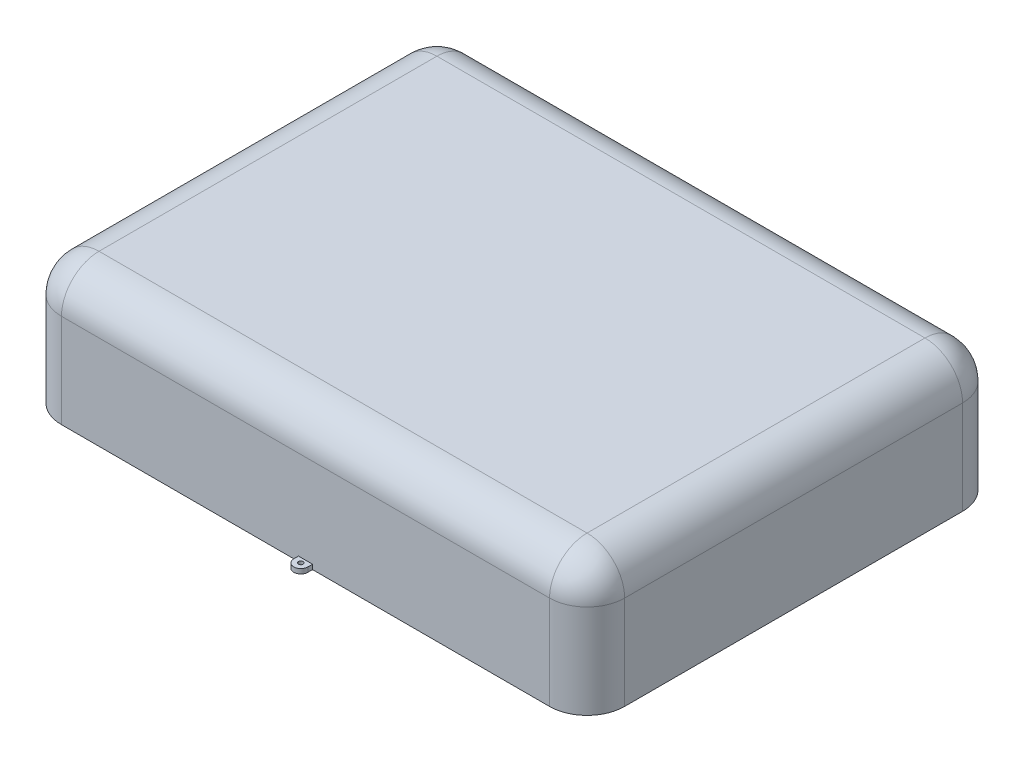
from build123d import *

# Parameters (mm, degrees)
SKETCH1_W                = 762
SKETCH1_H                = 558.8
BOSS_EXTRUDE1_DEPTH      = 177.8
FILLET9_R                = 50.8
SHELL1_T                 = -4.7625
SKETCH4_R                = 30.1625
BOSS_EXTRUDE3_DEPTH      = 77.7875
SKETCH5_R                = 25.4
SKETCH5_R_2              = 19.685
SKETCH5_R_3              = 14.9225
CUT_EXTRUDE1_DEPTH       = 12.7
FILLET13_R               = 2.54
SKETCH6_R                = 6.35
BOSS_EXTRUDE4_DEPTH      = 273.05
BOSS_EXTRUDE4_DEPTH_BACK = 273.05
SKETCH7_W                = 133.35
SKETCH7_H                = 19.05
SKETCH7_W_2              = 12.7
CUT_EXTRUDE2_DEPTH       = 203.2
CUT_EXTRUDE3_DEPTH       = 12.7
LPATTERN1_COUNT          = 3
LPATTERN1_PITCH          = 50.8
MIRROR1_COPY_1_DEPTH     = 12.7
MIRROR1_COPY_2_DEPTH     = 12.7
CUT_EXTRUDE4_DEPTH       = 12.7
LPATTERN2_COUNT          = 3
LPATTERN2_PITCH          = 50.8
MIRROR2_COPY_1_DEPTH     = 12.7
MIRROR2_COPY_2_DEPTH     = 12.7
FILLET14_R               = 2.54
SKETCH11_R               = 14.9225
CUT_EXTRUDE5_DEPTH       = 65.0875
BOSS_EXTRUDE5_DEPTH      = 1.27
LPATTERN3_COUNT          = 8
LPATTERN3_PITCH          = 43.18
LPATTERN3_COL_COUNT      = 8
LPATTERN3_COL_PITCH      = 43.18
MIRROR3_COPY_1_DEPTH     = 1.27
MIRROR3_COPY_2_DEPTH     = 1.27
MIRROR3_COPY_3_DEPTH     = 1.27
MIRROR3_COPY_4_DEPTH     = 1.27
MIRROR3_COPY_5_DEPTH     = 1.27
MIRROR3_COPY_6_DEPTH     = 1.27
MIRROR3_COPY_7_DEPTH     = 1.27
MIRROR3_COPY_8_DEPTH     = 1.27
MIRROR3_COPY_9_DEPTH     = 1.27
MIRROR3_COPY_10_DEPTH    = 1.27
MIRROR3_COPY_11_DEPTH    = 1.27
MIRROR3_COPY_12_DEPTH    = 1.27
MIRROR3_COPY_13_DEPTH    = 1.27
MIRROR3_COPY_14_DEPTH    = 1.27
BOSS_EXTRUDE6_DEPTH      = 1.27
LPATTERN4_COUNT          = 5
LPATTERN4_PITCH          = 44.45
LPATTERN4_COL_COUNT      = 5
LPATTERN4_COL_PITCH      = 44.45
MIRROR4_COPY_1_DEPTH     = 1.27
MIRROR4_COPY_2_DEPTH     = 1.27
MIRROR4_COPY_3_DEPTH     = 1.27
MIRROR4_COPY_4_DEPTH     = 1.27
MIRROR4_COPY_5_DEPTH     = 1.27
MIRROR4_COPY_6_DEPTH     = 1.27
MIRROR4_COPY_7_DEPTH     = 1.27
MIRROR4_COPY_8_DEPTH     = 1.27
SKETCH14_R               = 3.175
BOSS_EXTRUDE7_DEPTH      = 6.35


with BuildPart() as part:
    # Sketch1 → Boss-Extrude1 (new body)
    with BuildSketch(Plane(origin=(0, 0, 0), x_dir=(1, 0, 0), z_dir=(0, 1, 0))):
        Rectangle(SKETCH1_W, SKETCH1_H)
    extrude(amount=BOSS_EXTRUDE1_DEPTH)

    # Fillet9
    fillet9_edges = [part.edges().sort_by_distance(p)[0] for p in [
        (381, 177.8, 0),
        (0, 177.8, -279.4),
        (-381, 177.8, 0),
        (-381, 88.9, -279.4),
        (381, 88.9, -279.4),
        (381, 88.9, 279.4),
        (-381, 88.9, 279.4),
        (0, 177.8, 279.4),
    ]]
    fillet(fillet9_edges, radius=FILLET9_R)

    # Shell1
    shell1_openings = [part.faces().sort_by_distance(p)[0] for p in [
        (0, 0, 0),
    ]]
    offset(amount=SHELL1_T, openings=shell1_openings, kind=Kind.INTERSECTION)

    # Sketch4 → Boss-Extrude3 (add)
    with BuildSketch(Plane.XZ.offset(-173.0375)):
        with Locations((114.3, -68.58)):
            Circle(SKETCH4_R)
        with Locations((-114.3, -68.58)):
            Circle(SKETCH4_R)
        with Locations((114.3, 68.58)):
            Circle(SKETCH4_R)
        with Locations((-114.3, 68.58)):
            Circle(SKETCH4_R)
    extrude(amount=BOSS_EXTRUDE3_DEPTH)

    # Sketch5 → Cut-Extrude1 (cut)
    with BuildSketch(Plane.XZ.offset(-95.25)):
        with Locations((114.3, -68.58)):
            Circle(SKETCH5_R)
        with Locations((114.3, -68.58)):
            Circle(SKETCH5_R_2, mode=Mode.SUBTRACT)
        with Locations((114.3, -68.58)):
            Circle(SKETCH5_R_3)
        with Locations((-114.3, -68.58)):
            Circle(SKETCH5_R)
        with Locations((-114.3, -68.58)):
            Circle(SKETCH5_R_2, mode=Mode.SUBTRACT)
        with Locations((-114.3, -68.58)):
            Circle(SKETCH5_R_3)
        with Locations((114.3, 68.58)):
            Circle(SKETCH5_R)
        with Locations((114.3, 68.58)):
            Circle(SKETCH5_R_2, mode=Mode.SUBTRACT)
        with Locations((114.3, 68.58)):
            Circle(SKETCH5_R_3)
        with Locations((-114.3, 68.58)):
            Circle(SKETCH5_R)
        with Locations((-114.3, 68.58)):
            Circle(SKETCH5_R_2, mode=Mode.SUBTRACT)
        with Locations((-114.3, 68.58)):
            Circle(SKETCH5_R_3)
    extrude(amount=-CUT_EXTRUDE1_DEPTH, mode=Mode.SUBTRACT)

    # Fillet13
    fillet13_edges = [part.edges().sort_by_distance(p)[0] for p in [
        (84.1375, 173.0375, -68.58),
        (-144.4625, 173.0375, -68.58),
        (84.1375, 173.0375, 68.58),
        (-144.4625, 173.0375, 68.58),
    ]]
    fillet(fillet13_edges, radius=FILLET13_R)

    # Sketch6 → Boss-Extrude4 (add, two sides)
    with BuildSketch(Plane(origin=(0, 0, 0), x_dir=(0, 0, -1), z_dir=(1, 0, 0))) as boss_extrude4_sk:
        with BuildLine():
            Line((288.925, 9.525), (288.925, 30.48))
            Line((288.925, 30.48), (279.4, 30.48))
            Line((279.4, 30.48), (279.4, 0))
            ThreePointArc((279.4, 0), (295.660192091, -6.735192091), (288.925, 9.525))
        make_face()
        with Locations((288.925, 0)):
            Circle(SKETCH6_R, mode=Mode.SUBTRACT)
    extrude(amount=BOSS_EXTRUDE4_DEPTH)
    extrude(boss_extrude4_sk.sketch, amount=-BOSS_EXTRUDE4_DEPTH_BACK)

    # Sketch7 → Cut-Extrude2 (cut)
    with BuildSketch(Plane(origin=(0, 177.8, 0), x_dir=(1, 0, 0), z_dir=(0, 1, 0))):
        with Locations((66.675, 288.925)):
            Rectangle(SKETCH7_W, SKETCH7_H)
        with Locations((-66.675, 288.925)):
            Rectangle(SKETCH7_W, SKETCH7_H)
        with Locations((-152.4, 288.925)):
            Rectangle(SKETCH7_W_2, SKETCH7_H)
        with Locations((-177.8, 288.925)):
            Rectangle(SKETCH7_W_2, SKETCH7_H)
        with Locations((-203.2, 288.925)):
            Rectangle(SKETCH7_W_2, SKETCH7_H)
        with Locations((-228.6, 288.925)):
            Rectangle(SKETCH7_W_2, SKETCH7_H)
        with Locations((-254, 288.925)):
            Rectangle(SKETCH7_W_2, SKETCH7_H)
        with Locations((152.4, 288.925)):
            Rectangle(SKETCH7_W_2, SKETCH7_H)
        with Locations((177.8, 288.925)):
            Rectangle(SKETCH7_W_2, SKETCH7_H)
        with Locations((203.2, 288.925)):
            Rectangle(SKETCH7_W_2, SKETCH7_H)
        with Locations((228.6, 288.925)):
            Rectangle(SKETCH7_W_2, SKETCH7_H)
        with Locations((254, 288.925)):
            Rectangle(SKETCH7_W_2, SKETCH7_H)
    extrude(amount=-CUT_EXTRUDE2_DEPTH, mode=Mode.SUBTRACT)

    # Sketch8 → Cut-Extrude3 (cut)
    with BuildSketch(Plane.ZY.offset(273.05)):
        with BuildLine():
            Line((-288.925, 9.525), (-288.925, 30.48))
            Line((-288.925, 30.48), (-282.575, 30.48))
            Line((-282.575, 30.48), (-282.575, 7.099515829))
            ThreePointArc((-282.575, 7.099515829), (-285.526269595, 8.897991719), (-288.925, 9.525))
        make_face()
        with BuildLine():
            Line((-295.275, 0), (-298.45, 0))
            ThreePointArc((-298.45, 0), (-288.925, -9.525), (-279.4, 0))
            Line((-279.4, 0), (-282.575, 0))
            ThreePointArc((-282.575, 0), (-288.925, -6.35), (-295.275, 0))
        make_face()
    cut_extrude3 = extrude(amount=-CUT_EXTRUDE3_DEPTH, mode=Mode.SUBTRACT)

    # LPattern1: Cut-Extrude3 ×3
    with Locations(*[(i * LPATTERN1_PITCH, 0, 0) for i in range(1, LPATTERN1_COUNT)]):
        add(cut_extrude3, mode=Mode.SUBTRACT)

    # Mirror1: Cut-Extrude3 across plane
    add(cut_extrude3.mirror(Plane(origin=(0, 0, 0), x_dir=(0, 0, 1), z_dir=(1, 0, 0))), mode=Mode.SUBTRACT)

    # Mirror1 copy 1 sketch → Mirror1 copy 1 (cut)
    with BuildSketch(Plane(origin=(222.25, 0, 0), x_dir=(0, 0, 1), z_dir=(1, 0, 0))):
        with BuildLine():
            Line((-288.925, -9.525), (-288.925, -30.48))
            Line((-288.925, -30.48), (-282.575, -30.48))
            Line((-282.575, -30.48), (-282.575, -7.099515829))
            ThreePointArc((-282.575, -7.099515829), (-285.526269595, -8.897991719), (-288.925, -9.525))
        make_face()
        with BuildLine():
            Line((-295.275, 0), (-298.45, 0))
            ThreePointArc((-298.45, 0), (-288.925, 9.525), (-279.4, 0))
            Line((-279.4, 0), (-282.575, 0))
            ThreePointArc((-282.575, 0), (-288.925, 6.35), (-295.275, 0))
        make_face()
    extrude(amount=-MIRROR1_COPY_1_DEPTH, mode=Mode.SUBTRACT)

    # Mirror1 copy 2 sketch → Mirror1 copy 2 (cut)
    with BuildSketch(Plane(origin=(171.45, 0, 0), x_dir=(0, 0, 1), z_dir=(1, 0, 0))):
        with BuildLine():
            Line((-288.925, -9.525), (-288.925, -30.48))
            Line((-288.925, -30.48), (-282.575, -30.48))
            Line((-282.575, -30.48), (-282.575, -7.099515829))
            ThreePointArc((-282.575, -7.099515829), (-285.526269595, -8.897991719), (-288.925, -9.525))
        make_face()
        with BuildLine():
            Line((-295.275, 0), (-298.45, 0))
            ThreePointArc((-298.45, 0), (-288.925, 9.525), (-279.4, 0))
            Line((-279.4, 0), (-282.575, 0))
            ThreePointArc((-282.575, 0), (-288.925, 6.35), (-295.275, 0))
        make_face()
    extrude(amount=-MIRROR1_COPY_2_DEPTH, mode=Mode.SUBTRACT)

    # Sketch10 → Cut-Extrude4 (cut)
    with BuildSketch(Plane.ZY.offset(247.65)):
        with BuildLine():
            Line((-298.45, 0), (-295.275, 0))
            ThreePointArc((-295.275, 0), (-288.925, 6.35), (-282.575, 0))
            Line((-282.575, 0), (-282.575, 30.48))
            Line((-282.575, 30.48), (-288.925, 30.48))
            Line((-288.925, 30.48), (-288.925, 9.525))
            ThreePointArc((-288.925, 9.525), (-295.660192091, 6.735192091), (-298.45, 0))
        make_face()
    cut_extrude4 = extrude(amount=-CUT_EXTRUDE4_DEPTH, mode=Mode.SUBTRACT)

    # LPattern2: Cut-Extrude4 ×3
    with Locations(*[(i * LPATTERN2_PITCH, 0, 0) for i in range(1, LPATTERN2_COUNT)]):
        add(cut_extrude4, mode=Mode.SUBTRACT)

    # Mirror2: Cut-Extrude4 across plane
    add(cut_extrude4.mirror(Plane(origin=(0, 0, 0), x_dir=(0, 0, 1), z_dir=(1, 0, 0))), mode=Mode.SUBTRACT)

    # Mirror2 copy 1 sketch → Mirror2 copy 1 (cut)
    with BuildSketch(Plane(origin=(196.85, 0, 0), x_dir=(0, 0, 1), z_dir=(1, 0, 0))):
        with BuildLine():
            Line((-298.45, 0), (-295.275, 0))
            ThreePointArc((-295.275, 0), (-288.925, -6.35), (-282.575, 0))
            Line((-282.575, 0), (-282.575, -30.48))
            Line((-282.575, -30.48), (-288.925, -30.48))
            Line((-288.925, -30.48), (-288.925, -9.525))
            ThreePointArc((-288.925, -9.525), (-295.660192091, -6.735192091), (-298.45, 0))
        make_face()
    extrude(amount=-MIRROR2_COPY_1_DEPTH, mode=Mode.SUBTRACT)

    # Mirror2 copy 2 sketch → Mirror2 copy 2 (cut)
    with BuildSketch(Plane(origin=(146.05, 0, 0), x_dir=(0, 0, 1), z_dir=(1, 0, 0))):
        with BuildLine():
            Line((-298.45, 0), (-295.275, 0))
            ThreePointArc((-295.275, 0), (-288.925, -6.35), (-282.575, 0))
            Line((-282.575, 0), (-282.575, -30.48))
            Line((-282.575, -30.48), (-288.925, -30.48))
            Line((-288.925, -30.48), (-288.925, -9.525))
            ThreePointArc((-288.925, -9.525), (-295.660192091, -6.735192091), (-298.45, 0))
        make_face()
    extrude(amount=-MIRROR2_COPY_2_DEPTH, mode=Mode.SUBTRACT)

    # Fillet14
    fillet14_edges = [part.edges().sort_by_distance(p)[0] for p in [
        (-241.3, 0, -279.4),
        (-190.5, 0, -279.4),
        (-139.7, 0, -279.4),
        (139.7, 0, -279.4),
        (190.5, 0, -279.4),
        (241.3, 0, -279.4),
        (-266.7, 7.099515829, -282.575),
        (-215.9, 7.099515829, -282.575),
        (-165.1, 7.099515829, -282.575),
        (266.7, 7.099515829, -282.575),
        (215.9, 7.099515829, -282.575),
        (165.1, 7.099515829, -282.575),
    ]]
    fillet(fillet14_edges, radius=FILLET14_R)

    # Sketch11 → Cut-Extrude5 (cut)
    with BuildSketch(Plane.XZ.offset(-107.95)):
        with Locations((-114.3, 68.58)):
            Circle(SKETCH11_R)
        with Locations((-114.3, -68.58)):
            Circle(SKETCH11_R)
        with Locations((114.3, -68.58)):
            Circle(SKETCH11_R)
        with Locations((114.3, 68.58)):
            Circle(SKETCH11_R)
    extrude(amount=-CUT_EXTRUDE5_DEPTH, mode=Mode.SUBTRACT)

    # Sketch12 → Boss-Extrude5 (add, symmetric)
    with BuildSketch(Plane(origin=(0, 0, 0), x_dir=(0, 0, -1), z_dir=(1, 0, 0))):
        with BuildLine():
            Line((228.6, 173.0375), (274.6375, 109.5375))
            Line((274.6375, 109.5375), (274.6375, 127))
            ThreePointArc((274.6375, 127), (261.153428439, 159.553428439), (228.6, 173.0375))
        make_face()
    boss_extrude5 = extrude(amount=BOSS_EXTRUDE5_DEPTH, both=True)

    # LPattern3: Boss-Extrude5 ×8
    with Locations(*[(i * LPATTERN3_PITCH, 0, 0) for i in range(1, LPATTERN3_COUNT)]):
        add(boss_extrude5)

    # LPattern3 col: Boss-Extrude5 ×8
    with Locations(*[(-i * LPATTERN3_COL_PITCH, 0, 0) for i in range(1, LPATTERN3_COL_COUNT)]):
        add(boss_extrude5)

    # Mirror3: Boss-Extrude5 across plane
    add(boss_extrude5.mirror(Plane.XY))

    # Mirror3 copy 1 sketch → Mirror3 copy 1 (add, symmetric)
    with BuildSketch(Plane(origin=(43.18, 0, 0), x_dir=(0, 0, 1), z_dir=(1, 0, 0))):
        with BuildLine():
            Line((228.6, -173.0375), (274.6375, -109.5375))
            Line((274.6375, -109.5375), (274.6375, -127))
            ThreePointArc((274.6375, -127), (261.153428439, -159.553428439), (228.6, -173.0375))
        make_face()
    extrude(amount=MIRROR3_COPY_1_DEPTH, both=True)

    # Mirror3 copy 2 sketch → Mirror3 copy 2 (add, symmetric)
    with BuildSketch(Plane(origin=(86.36, 0, 0), x_dir=(0, 0, 1), z_dir=(1, 0, 0))):
        with BuildLine():
            Line((228.6, -173.0375), (274.6375, -109.5375))
            Line((274.6375, -109.5375), (274.6375, -127))
            ThreePointArc((274.6375, -127), (261.153428439, -159.553428439), (228.6, -173.0375))
        make_face()
    extrude(amount=MIRROR3_COPY_2_DEPTH, both=True)

    # Mirror3 copy 3 sketch → Mirror3 copy 3 (add, symmetric)
    with BuildSketch(Plane(origin=(129.54, 0, 0), x_dir=(0, 0, 1), z_dir=(1, 0, 0))):
        with BuildLine():
            Line((228.6, -173.0375), (274.6375, -109.5375))
            Line((274.6375, -109.5375), (274.6375, -127))
            ThreePointArc((274.6375, -127), (261.153428439, -159.553428439), (228.6, -173.0375))
        make_face()
    extrude(amount=MIRROR3_COPY_3_DEPTH, both=True)

    # Mirror3 copy 4 sketch → Mirror3 copy 4 (add, symmetric)
    with BuildSketch(Plane(origin=(172.72, 0, 0), x_dir=(0, 0, 1), z_dir=(1, 0, 0))):
        with BuildLine():
            Line((228.6, -173.0375), (274.6375, -109.5375))
            Line((274.6375, -109.5375), (274.6375, -127))
            ThreePointArc((274.6375, -127), (261.153428439, -159.553428439), (228.6, -173.0375))
        make_face()
    extrude(amount=MIRROR3_COPY_4_DEPTH, both=True)

    # Mirror3 copy 5 sketch → Mirror3 copy 5 (add, symmetric)
    with BuildSketch(Plane(origin=(215.9, 0, 0), x_dir=(0, 0, 1), z_dir=(1, 0, 0))):
        with BuildLine():
            Line((228.6, -173.0375), (274.6375, -109.5375))
            Line((274.6375, -109.5375), (274.6375, -127))
            ThreePointArc((274.6375, -127), (261.153428439, -159.553428439), (228.6, -173.0375))
        make_face()
    extrude(amount=MIRROR3_COPY_5_DEPTH, both=True)

    # Mirror3 copy 6 sketch → Mirror3 copy 6 (add, symmetric)
    with BuildSketch(Plane(origin=(259.08, 0, 0), x_dir=(0, 0, 1), z_dir=(1, 0, 0))):
        with BuildLine():
            Line((228.6, -173.0375), (274.6375, -109.5375))
            Line((274.6375, -109.5375), (274.6375, -127))
            ThreePointArc((274.6375, -127), (261.153428439, -159.553428439), (228.6, -173.0375))
        make_face()
    extrude(amount=MIRROR3_COPY_6_DEPTH, both=True)

    # Mirror3 copy 7 sketch → Mirror3 copy 7 (add, symmetric)
    with BuildSketch(Plane(origin=(302.26, 0, 0), x_dir=(0, 0, 1), z_dir=(1, 0, 0))):
        with BuildLine():
            Line((228.6, -173.0375), (274.6375, -109.5375))
            Line((274.6375, -109.5375), (274.6375, -127))
            ThreePointArc((274.6375, -127), (261.153428439, -159.553428439), (228.6, -173.0375))
        make_face()
    extrude(amount=MIRROR3_COPY_7_DEPTH, both=True)

    # Mirror3 copy 8 sketch → Mirror3 copy 8 (add, symmetric)
    with BuildSketch(Plane(origin=(-43.18, 0, 0), x_dir=(0, 0, 1), z_dir=(1, 0, 0))):
        with BuildLine():
            Line((228.6, -173.0375), (274.6375, -109.5375))
            Line((274.6375, -109.5375), (274.6375, -127))
            ThreePointArc((274.6375, -127), (261.153428439, -159.553428439), (228.6, -173.0375))
        make_face()
    extrude(amount=MIRROR3_COPY_8_DEPTH, both=True)

    # Mirror3 copy 9 sketch → Mirror3 copy 9 (add, symmetric)
    with BuildSketch(Plane(origin=(-86.36, 0, 0), x_dir=(0, 0, 1), z_dir=(1, 0, 0))):
        with BuildLine():
            Line((228.6, -173.0375), (274.6375, -109.5375))
            Line((274.6375, -109.5375), (274.6375, -127))
            ThreePointArc((274.6375, -127), (261.153428439, -159.553428439), (228.6, -173.0375))
        make_face()
    extrude(amount=MIRROR3_COPY_9_DEPTH, both=True)

    # Mirror3 copy 10 sketch → Mirror3 copy 10 (add, symmetric)
    with BuildSketch(Plane(origin=(-129.54, 0, 0), x_dir=(0, 0, 1), z_dir=(1, 0, 0))):
        with BuildLine():
            Line((228.6, -173.0375), (274.6375, -109.5375))
            Line((274.6375, -109.5375), (274.6375, -127))
            ThreePointArc((274.6375, -127), (261.153428439, -159.553428439), (228.6, -173.0375))
        make_face()
    extrude(amount=MIRROR3_COPY_10_DEPTH, both=True)

    # Mirror3 copy 11 sketch → Mirror3 copy 11 (add, symmetric)
    with BuildSketch(Plane(origin=(-172.72, 0, 0), x_dir=(0, 0, 1), z_dir=(1, 0, 0))):
        with BuildLine():
            Line((228.6, -173.0375), (274.6375, -109.5375))
            Line((274.6375, -109.5375), (274.6375, -127))
            ThreePointArc((274.6375, -127), (261.153428439, -159.553428439), (228.6, -173.0375))
        make_face()
    extrude(amount=MIRROR3_COPY_11_DEPTH, both=True)

    # Mirror3 copy 12 sketch → Mirror3 copy 12 (add, symmetric)
    with BuildSketch(Plane(origin=(-215.9, 0, 0), x_dir=(0, 0, 1), z_dir=(1, 0, 0))):
        with BuildLine():
            Line((228.6, -173.0375), (274.6375, -109.5375))
            Line((274.6375, -109.5375), (274.6375, -127))
            ThreePointArc((274.6375, -127), (261.153428439, -159.553428439), (228.6, -173.0375))
        make_face()
    extrude(amount=MIRROR3_COPY_12_DEPTH, both=True)

    # Mirror3 copy 13 sketch → Mirror3 copy 13 (add, symmetric)
    with BuildSketch(Plane(origin=(-259.08, 0, 0), x_dir=(0, 0, 1), z_dir=(1, 0, 0))):
        with BuildLine():
            Line((228.6, -173.0375), (274.6375, -109.5375))
            Line((274.6375, -109.5375), (274.6375, -127))
            ThreePointArc((274.6375, -127), (261.153428439, -159.553428439), (228.6, -173.0375))
        make_face()
    extrude(amount=MIRROR3_COPY_13_DEPTH, both=True)

    # Mirror3 copy 14 sketch → Mirror3 copy 14 (add, symmetric)
    with BuildSketch(Plane(origin=(-302.26, 0, 0), x_dir=(0, 0, 1), z_dir=(1, 0, 0))):
        with BuildLine():
            Line((228.6, -173.0375), (274.6375, -109.5375))
            Line((274.6375, -109.5375), (274.6375, -127))
            ThreePointArc((274.6375, -127), (261.153428439, -159.553428439), (228.6, -173.0375))
        make_face()
    extrude(amount=MIRROR3_COPY_14_DEPTH, both=True)

    # Sketch13 → Boss-Extrude6 (add, symmetric)
    with BuildSketch(Plane.XY):
        with BuildLine():
            Line((330.2, 173.0375), (376.2375, 109.5375))
            Line((376.2375, 109.5375), (376.2375, 127))
            ThreePointArc((376.2375, 127), (362.753428439, 159.553428439), (330.2, 173.0375))
        make_face()
    boss_extrude6 = extrude(amount=BOSS_EXTRUDE6_DEPTH, both=True)

    # LPattern4: Boss-Extrude6 ×5
    with Locations(*[(0, 0, i * LPATTERN4_PITCH) for i in range(1, LPATTERN4_COUNT)]):
        add(boss_extrude6)

    # LPattern4 col: Boss-Extrude6 ×5
    with Locations(*[(0, 0, -i * LPATTERN4_COL_PITCH) for i in range(1, LPATTERN4_COL_COUNT)]):
        add(boss_extrude6)

    # Mirror4: Boss-Extrude6 across plane
    add(boss_extrude6.mirror(Plane(origin=(0, 0, 0), x_dir=(0, 0, 1), z_dir=(1, 0, 0))))

    # Mirror4 copy 1 sketch → Mirror4 copy 1 (add, symmetric)
    with BuildSketch(Plane(origin=(0, 0, 44.45), x_dir=(-1, 0, 0), z_dir=(0, 0, 1))):
        with BuildLine():
            Line((330.2, -173.0375), (376.2375, -109.5375))
            Line((376.2375, -109.5375), (376.2375, -127))
            ThreePointArc((376.2375, -127), (362.753428439, -159.553428439), (330.2, -173.0375))
        make_face()
    extrude(amount=MIRROR4_COPY_1_DEPTH, both=True)

    # Mirror4 copy 2 sketch → Mirror4 copy 2 (add, symmetric)
    with BuildSketch(Plane(origin=(0, 0, 88.9), x_dir=(-1, 0, 0), z_dir=(0, 0, 1))):
        with BuildLine():
            Line((330.2, -173.0375), (376.2375, -109.5375))
            Line((376.2375, -109.5375), (376.2375, -127))
            ThreePointArc((376.2375, -127), (362.753428439, -159.553428439), (330.2, -173.0375))
        make_face()
    extrude(amount=MIRROR4_COPY_2_DEPTH, both=True)

    # Mirror4 copy 3 sketch → Mirror4 copy 3 (add, symmetric)
    with BuildSketch(Plane(origin=(0, 0, 133.35), x_dir=(-1, 0, 0), z_dir=(0, 0, 1))):
        with BuildLine():
            Line((330.2, -173.0375), (376.2375, -109.5375))
            Line((376.2375, -109.5375), (376.2375, -127))
            ThreePointArc((376.2375, -127), (362.753428439, -159.553428439), (330.2, -173.0375))
        make_face()
    extrude(amount=MIRROR4_COPY_3_DEPTH, both=True)

    # Mirror4 copy 4 sketch → Mirror4 copy 4 (add, symmetric)
    with BuildSketch(Plane(origin=(0, 0, 177.8), x_dir=(-1, 0, 0), z_dir=(0, 0, 1))):
        with BuildLine():
            Line((330.2, -173.0375), (376.2375, -109.5375))
            Line((376.2375, -109.5375), (376.2375, -127))
            ThreePointArc((376.2375, -127), (362.753428439, -159.553428439), (330.2, -173.0375))
        make_face()
    extrude(amount=MIRROR4_COPY_4_DEPTH, both=True)

    # Mirror4 copy 5 sketch → Mirror4 copy 5 (add, symmetric)
    with BuildSketch(Plane(origin=(0, 0, -44.45), x_dir=(-1, 0, 0), z_dir=(0, 0, 1))):
        with BuildLine():
            Line((330.2, -173.0375), (376.2375, -109.5375))
            Line((376.2375, -109.5375), (376.2375, -127))
            ThreePointArc((376.2375, -127), (362.753428439, -159.553428439), (330.2, -173.0375))
        make_face()
    extrude(amount=MIRROR4_COPY_5_DEPTH, both=True)

    # Mirror4 copy 6 sketch → Mirror4 copy 6 (add, symmetric)
    with BuildSketch(Plane(origin=(0, 0, -88.9), x_dir=(-1, 0, 0), z_dir=(0, 0, 1))):
        with BuildLine():
            Line((330.2, -173.0375), (376.2375, -109.5375))
            Line((376.2375, -109.5375), (376.2375, -127))
            ThreePointArc((376.2375, -127), (362.753428439, -159.553428439), (330.2, -173.0375))
        make_face()
    extrude(amount=MIRROR4_COPY_6_DEPTH, both=True)

    # Mirror4 copy 7 sketch → Mirror4 copy 7 (add, symmetric)
    with BuildSketch(Plane(origin=(0, 0, -133.35), x_dir=(-1, 0, 0), z_dir=(0, 0, 1))):
        with BuildLine():
            Line((330.2, -173.0375), (376.2375, -109.5375))
            Line((376.2375, -109.5375), (376.2375, -127))
            ThreePointArc((376.2375, -127), (362.753428439, -159.553428439), (330.2, -173.0375))
        make_face()
    extrude(amount=MIRROR4_COPY_7_DEPTH, both=True)

    # Mirror4 copy 8 sketch → Mirror4 copy 8 (add, symmetric)
    with BuildSketch(Plane(origin=(0, 0, -177.8), x_dir=(-1, 0, 0), z_dir=(0, 0, 1))):
        with BuildLine():
            Line((330.2, -173.0375), (376.2375, -109.5375))
            Line((376.2375, -109.5375), (376.2375, -127))
            ThreePointArc((376.2375, -127), (362.753428439, -159.553428439), (330.2, -173.0375))
        make_face()
    extrude(amount=MIRROR4_COPY_8_DEPTH, both=True)

    # Sketch14 → Boss-Extrude7 (add)
    with BuildSketch(Plane(origin=(0, 0, 0), x_dir=(1, 0, 0), z_dir=(0, 1, 0))):
        with BuildLine():
            Line((9.525, -285.75), (9.525, -279.4))
            Line((9.525, -279.4), (-9.525, -279.4))
            Line((-9.525, -279.4), (-9.525, -285.75))
            ThreePointArc((-9.525, -285.75), (0, -295.275), (9.525, -285.75))
        make_face()
        with Locations((0, -285.75)):
            Circle(SKETCH14_R, mode=Mode.SUBTRACT)
    extrude(amount=BOSS_EXTRUDE7_DEPTH)


solid = part.part
